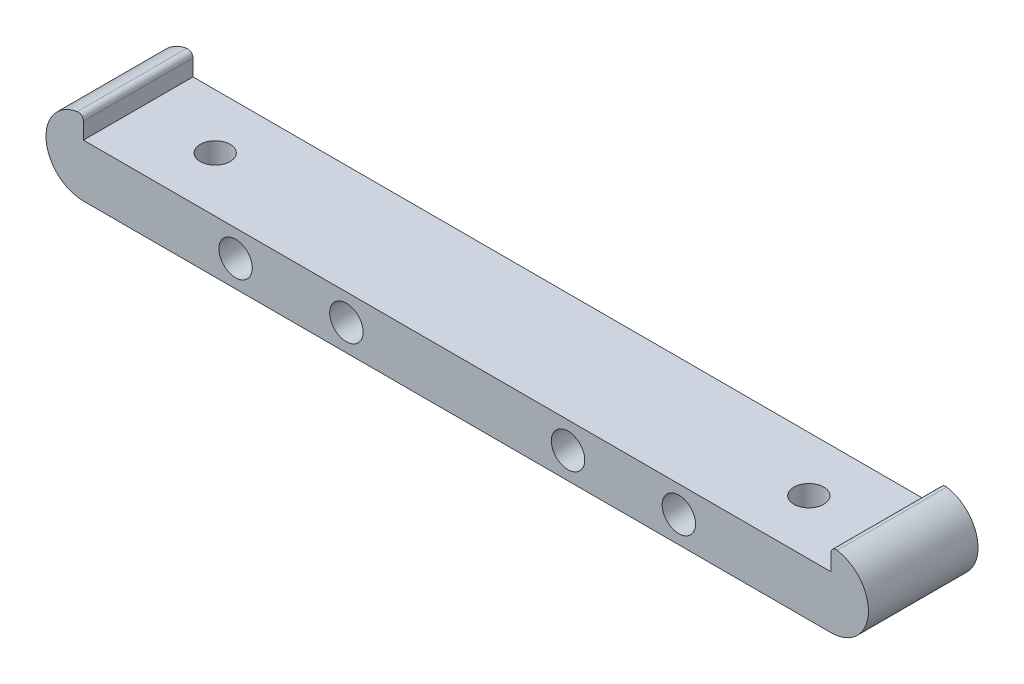
from build123d import *

# Parameters (mm, degrees)
SKETCH1_R           = 2.413
BOSS_EXTRUDE1_DEPTH = 15.8242
SKETCH3_R           = 2.159
CUT_EXTRUDE1_DEPTH  = 7.62
FILLET1_R           = 0.762


with BuildPart() as part:
    # Sketch1 → Boss-Extrude1 (new body)
    with BuildSketch(Plane.XY):
        with BuildLine():
            Line((0, 7.62), (107.95, 7.62))
            Line((107.95, 7.62), (107.95, 10.8204))
            ThreePointArc((107.95, 10.8204), (113.3602, 5.4102), (107.95, 0))
            Line((107.95, 0), (0, 0))
            ThreePointArc((0, 0), (-5.4102, 5.4102), (0, 10.8204))
            Line((0, 10.8204), (0, 7.62))
        make_face()
        with Locations((21.971, 3.81)):
            Circle(SKETCH1_R, mode=Mode.SUBTRACT)
        with Locations((37.973, 3.81)):
            Circle(SKETCH1_R, mode=Mode.SUBTRACT)
        with Locations((69.977, 3.81)):
            Circle(SKETCH1_R, mode=Mode.SUBTRACT)
        with Locations((85.979, 3.81)):
            Circle(SKETCH1_R, mode=Mode.SUBTRACT)
    extrude(amount=BOSS_EXTRUDE1_DEPTH)

    # Sketch3 → Cut-Extrude1 (cut)
    with BuildSketch(Plane(origin=(0, 7.62, 0), x_dir=(1, 0, 0), z_dir=(0, 1, 0))):
        with Locations((96.8375, -7.9121)):
            Circle(SKETCH3_R)
        with Locations((11.1125, -7.9121)):
            Circle(SKETCH3_R)
    extrude(amount=-CUT_EXTRUDE1_DEPTH, mode=Mode.SUBTRACT)

    # Fillet1
    fillet1_edges = [part.edges().sort_by_distance(p)[0] for p in [
        (0, 10.8204, 7.9121),
        (107.95, 10.8204, 7.9121),
    ]]
    fillet(fillet1_edges, radius=FILLET1_R)


solid = part.part
